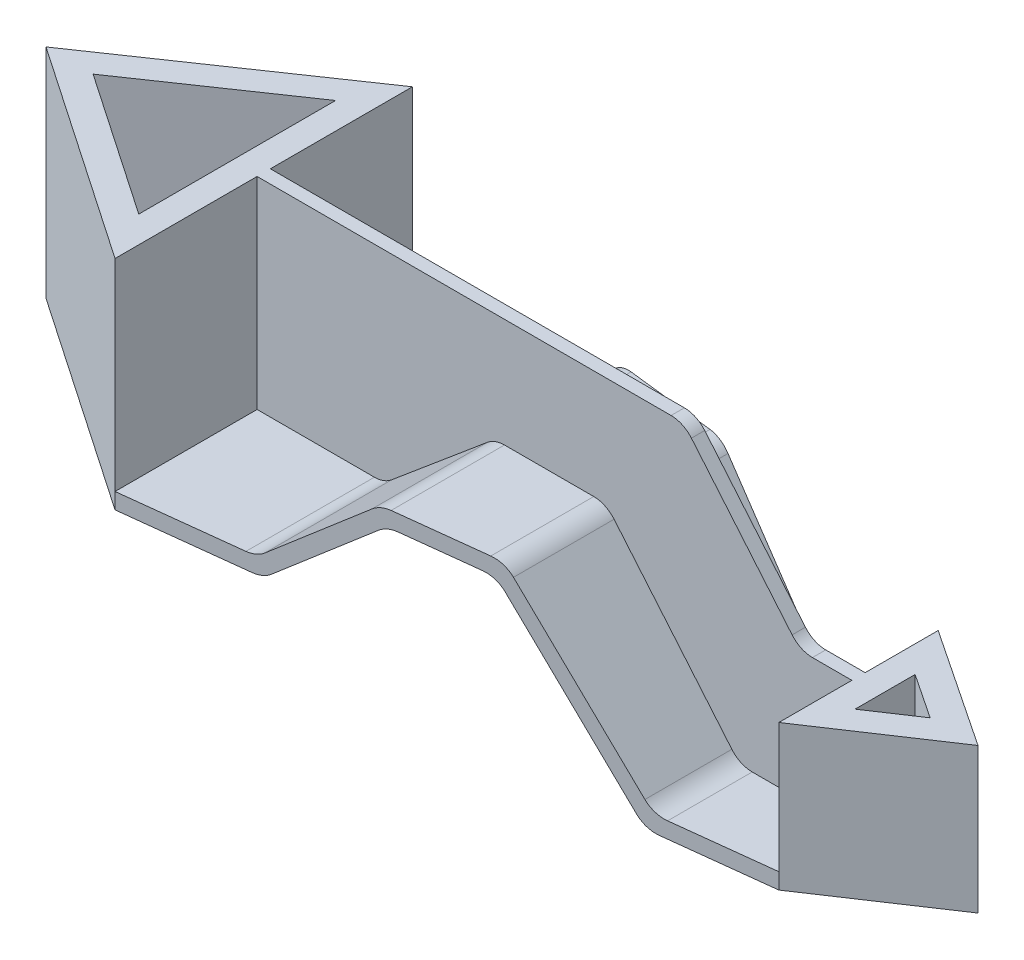
from build123d import *

# Parameters (mm, degrees)
BOSS_EXTRUDE1_DEPTH     = 82
BOSS_EXTRUDE2_DEPTH     = 56
BOSS_EXTRUDE3_START     = -25
BOSS_EXTRUDE3_DEPTH     = 54.666666667
BOSS_EXTRUDE4_DEPTH     = 2.5
CUT_EXTRUDE2_DEPTH      = 83
CUT_EXTRUDE2_DEPTH_BACK = 26
FILLET1_R               = 10


with BuildPart() as part:
    # Sketch2 → Boss-Extrude1 (new body)
    with BuildSketch(Plane(origin=(0, 0, 0), x_dir=(1, 0, 0), z_dir=(0, 1, 0))):
        Polygon((0, -56), (0, 56), (-82, 0), align=None)
        Polygon((-10, 37.0612765), (-64.268297732, 0), (-10, -37.0612765), align=None, mode=Mode.SUBTRACT)
    extrude(amount=BOSS_EXTRUDE1_DEPTH)

    # Sketch3 → Boss-Extrude2 (add, symmetric)
    with BuildSketch(Plane.XY):
        Polygon((0, 0), (50, 0), (91.711375741, 35), (128.654022129, 35), (179, -25), (224, -25), (224, -19), (181.797845949, -19), (131.451868078, 41), (89.527554335, 41), (47.816178594, 6), (0, 6), align=None)
    extrude(amount=BOSS_EXTRUDE2_DEPTH, both=True)

    # Sketch4 → Boss-Extrude3 (add)
    with BuildSketch(Plane(origin=(0, 0, 0), x_dir=(1, 0, 0), z_dir=(0, 1, 0)).offset(BOSS_EXTRUDE3_START)):
        Polygon((224, -30), (224, 30), (269, 0), align=None)
        Polygon((234, 11.314829082), (250.972243623, 0), (234, -11.314829082), align=None, mode=Mode.SUBTRACT)
    extrude(amount=BOSS_EXTRUDE3_DEPTH)

    # Sketch7 → Boss-Extrude4 (add, symmetric)
    with BuildSketch(Plane.XY):
        Polygon((0, 82), (160.578604614, 82), (204.491485312, 29.666666667), (224, 29.666666667), (224, -19), (181.797845949, -19), (131.451868078, 41), (89.527554335, 41), (47.816178594, 6), (0, 6), align=None)
    extrude(amount=BOSS_EXTRUDE4_DEPTH, both=True)

    # Sketch8 → Cut-Extrude2 (cut, two sides)
    with BuildSketch(Plane(origin=(0, 0, 0), x_dir=(1, 0, 0), z_dir=(0, 1, 0))) as cut_extrude2_sk:
        Polygon((0, 56), (224, 56), (224, 30), align=None)
        Polygon((0, -56), (224, -30), (224, -56), align=None)
    extrude(amount=CUT_EXTRUDE2_DEPTH, mode=Mode.SUBTRACT)
    extrude(cut_extrude2_sk.sketch, amount=-CUT_EXTRUDE2_DEPTH_BACK, mode=Mode.SUBTRACT)

    # Fillet1
    fillet1_edges = [part.edges().sort_by_distance(p)[0] for p in [
        (47.816178594, 6, 26.474953921),
        (89.527554335, 41, 24.054204436),
        (131.451868078, 41, 21.621096942),
        (181.797845949, -19, 18.699232155),
        (179, -25, 0),
        (128.654022129, 35, 0),
        (91.711375741, 35, 0),
        (50, 0, 0),
        (47.816178594, 6, -26.474953921),
        (89.527554335, 41, -24.054204436),
        (131.451868078, 41, -21.621096942),
        (181.797845949, -19, -18.699232155),
        (204.491485312, 29.666666667, 0),
        (160.578604614, 82, 0),
    ]]
    fillet(fillet1_edges, radius=FILLET1_R)


solid = part.part
